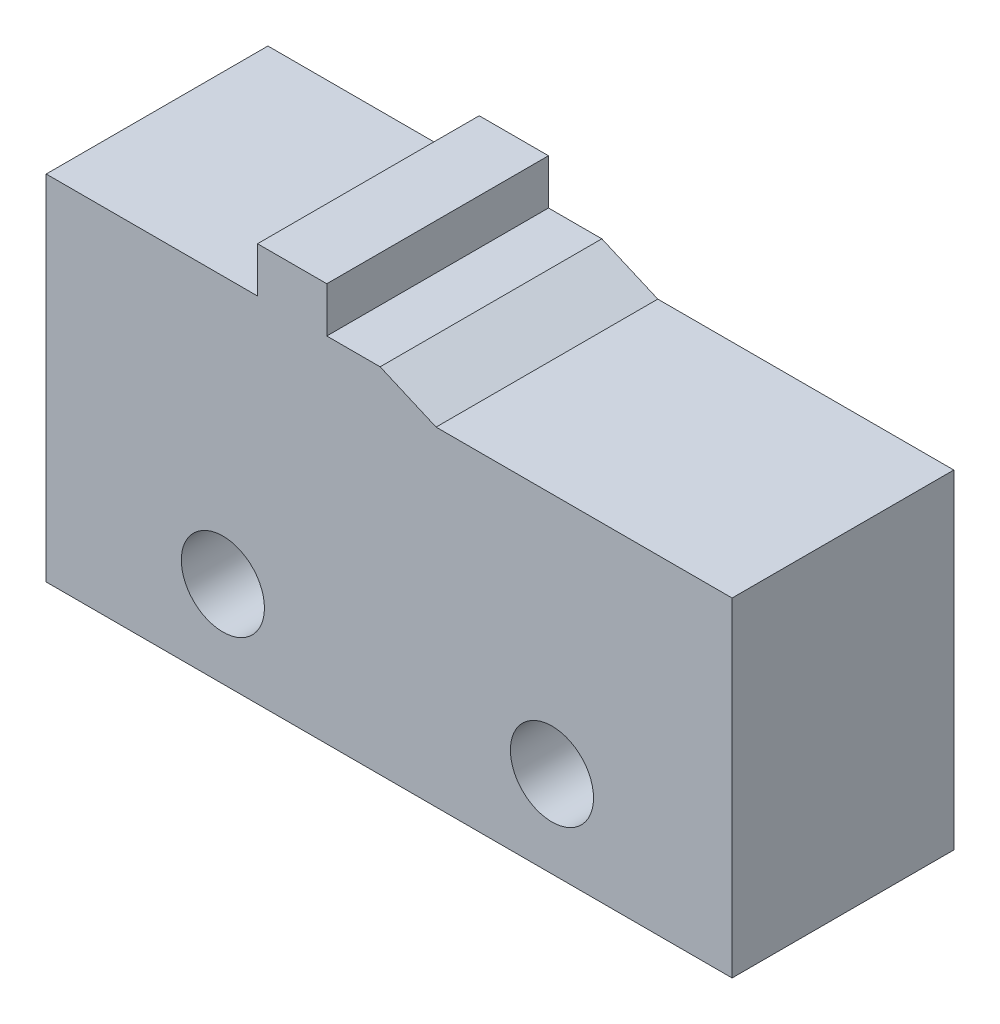
from build123d import *

# Parameters (mm, degrees)
SKETCH1_R           = 1.2
BOSS_EXTRUDE1_DEPTH = 6.4


with BuildPart() as part:
    # Sketch1 → Boss-Extrude1 (new body)
    with BuildSketch(Plane.XY):
        Polygon((0, 0), (19.8, 0), (19.8, 9.5), (11.254760895, 9.5), (9.639986457, 10.2), (8.1, 10.2), (8.1, 11.506737858), (6.1, 11.506737858), (6.1, 10.2), (0, 10.2), align=None)
        with Locations((5.1, 2.5)):
            Circle(SKETCH1_R, mode=Mode.SUBTRACT)
        with Locations((14.6, 2.5)):
            Circle(SKETCH1_R, mode=Mode.SUBTRACT)
    extrude(amount=BOSS_EXTRUDE1_DEPTH)


solid = part.part
